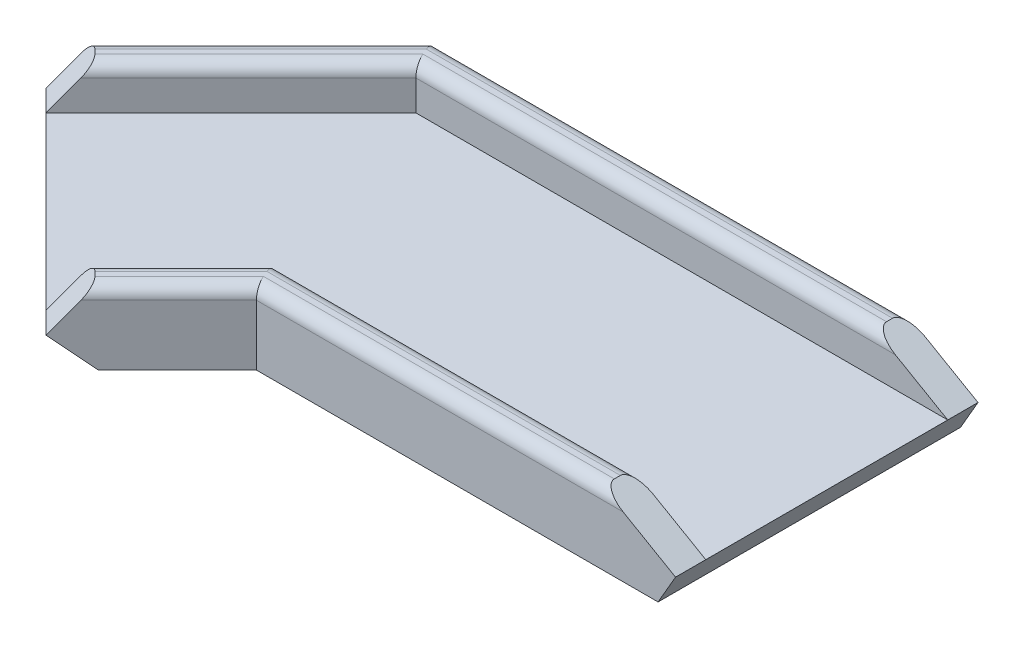
from build123d import *

# Parameters (mm, degrees)
SKETCH1_W               = 114.3
SKETCH1_H               = 6.35
BOSS_EXTRUDE1_DEPTH     = 63.5
SKETCH2_W               = 114.3
SKETCH2_H               = 6.35
BOSS_EXTRUDE2_DEPTH     = 8.89
CUT_EXTRUDE1_DEPTH      = 64.5
CUT_EXTRUDE2_DEPTH      = 13.065
CUT_EXTRUDE2_DEPTH_BACK = 4.175
BOSS_EXTRUDE4_DEPTH     = 3.175
BOSS_EXTRUDE5_DEPTH     = 8.89
FILLET1_R               = 2.54
CUT_EXTRUDE3_DEPTH      = 93.267614143


with BuildPart() as part:
    # Sketch1 → Boss-Extrude1 (new body)
    with BuildSketch(Plane.XY):
        Rectangle(SKETCH1_W, SKETCH1_H)
    extrude(amount=-BOSS_EXTRUDE1_DEPTH)

    # Sketch2 → Boss-Extrude2 (add)
    with BuildSketch(Plane(origin=(0, 3.175, 0), x_dir=(1, 0, 0), z_dir=(0, 1, 0))):
        with Locations((0, 60.325)):
            Rectangle(SKETCH2_W, SKETCH2_H)
        with Locations((0, 3.175)):
            Rectangle(SKETCH2_W, SKETCH2_H)
    extrude(amount=BOSS_EXTRUDE2_DEPTH)

    # Sketch3 → Cut-Extrude1 (cut, through all)
    with BuildSketch(Plane.XY):
        Polygon((57.15, 3.175), (41.752068321, 12.065), (48.527437664, 23.800283942), (66.675, 13.322783942), (57.15, -3.175), (56.233456448, -4.7625), (53.483825791, -3.175), align=None)
    extrude(amount=-CUT_EXTRUDE1_DEPTH, mode=Mode.SUBTRACT)

    # Sketch5 → Cut-Extrude2 (cut, two sides)
    with BuildSketch(Plane(origin=(0, 0, 0), x_dir=(1, 0, 0), z_dir=(0, 1, 0))) as cut_extrude2_sk:
        Polygon((-57.15, 63.5), (-30.847438789, 0), (-57.15, 0), align=None)
    extrude(amount=CUT_EXTRUDE2_DEPTH, mode=Mode.SUBTRACT)
    extrude(cut_extrude2_sk.sketch, amount=-CUT_EXTRUDE2_DEPTH_BACK, mode=Mode.SUBTRACT)

    # Sketch9 → Boss-Extrude4 (add, symmetric)
    with BuildSketch(Plane(origin=(0, 0, 0), x_dir=(1, 0, 0), z_dir=(0, 1, 0))):
        Polygon((-30.847438789, 0), (-57.15, 63.5), (-97.833550078, 22.816449922), (-52.932269473, -22.084830683), align=None)
    extrude(amount=BOSS_EXTRUDE4_DEPTH, both=True)

    # Sketch11 → Boss-Extrude5 (add)
    with BuildSketch(Plane(origin=(0, 3.175, 0), x_dir=(1, 0, 0), z_dir=(0, 1, 0))):
        Polygon((-57.15, 63.5), (-97.833550078, 22.816449922), (-93.343422018, 18.326321861), (-54.519743879, 57.15), align=None)
        Polygon((-33.47769491, 6.35), (-57.422397533, -17.594702623), (-52.932269473, -22.084830683), (-30.847438789, 0), align=None)
    extrude(amount=BOSS_EXTRUDE5_DEPTH)

    # Fillet1
    fillet1_edges = [part.edges().sort_by_distance(p)[0] for p in [
        (-41.889854131, 12.065, 11.042415342),
        (5.452314766, 12.065, 0),
        (4.137186705, 12.065, -6.35),
        (-45.450046222, 12.065, 5.622351311),
        (-73.931582948, 12.065, -37.738160931),
        (-6.383837779, 12.065, -57.15),
        (-7.69896584, 12.065, -63.5),
        (-77.491775039, 12.065, -43.158224961),
    ]]
    fillet(fillet1_edges, radius=FILLET1_R)

    # Sketch12 → Cut-Extrude3 (cut, through all)
    with BuildSketch(Plane(origin=(-15.423719395, 0, -15.423719395), x_dir=(0.707106781, 0, -0.707106781), z_dir=(0.707106781, 0, 0.707106781))):
        Polygon((-53.045100225, 3.175), (-45.267970292, -3.175), (-53.300155549, -13.012377699), (-72.974910948, 3.051992814), (-56.910540434, 22.726748213), (-45.012914969, 13.012377699), align=None)
    extrude(amount=-CUT_EXTRUDE3_DEPTH, mode=Mode.SUBTRACT)


solid = part.part
